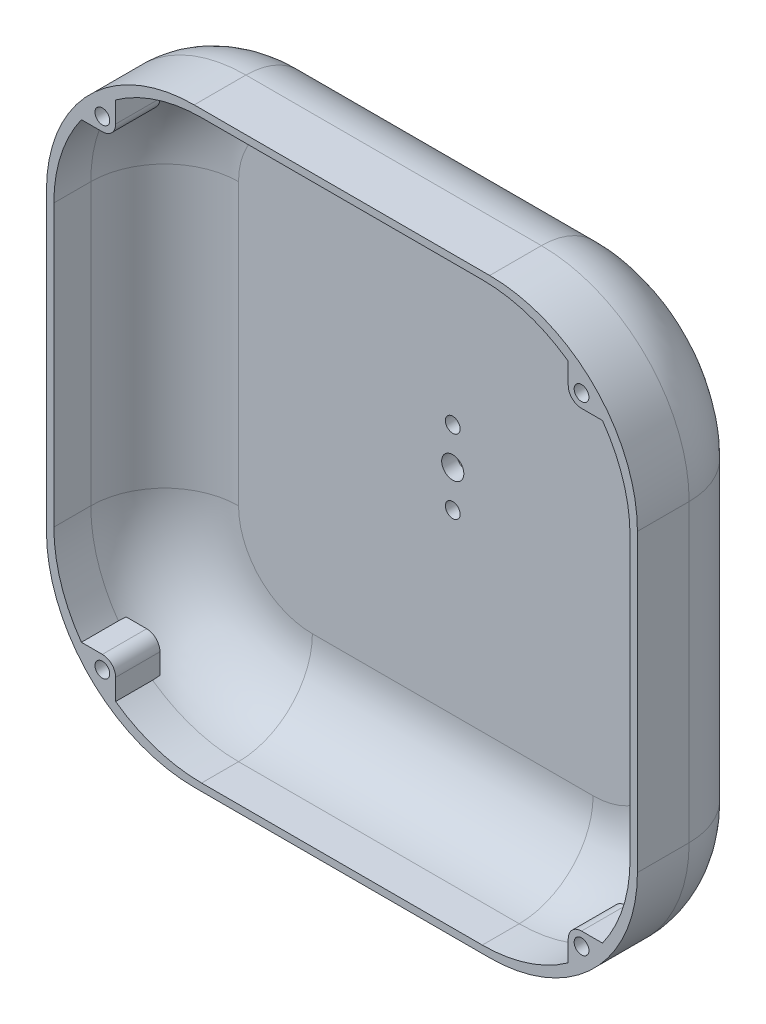
from build123d import *

# Parameters (mm, degrees)
SKETCH1_W           = 80
SKETCH1_H           = 80
BOSS_EXTRUDE1_DEPTH = 2
SKETCH2_W           = 80
SKETCH2_H           = 80
SKETCH2_W_2         = 78
SKETCH2_H_2         = 78
BOSS_EXTRUDE2_DEPTH = 15
FILLET1_R           = 20
FILLET2_R           = 10
FILLET3_R           = 20
FILLET4_R           = 10
SKETCH3_R           = 1
BOSS_EXTRUDE3_DEPTH = 6
SKETCH4_W           = 10
SKETCH4_H           = 10
BOSS_EXTRUDE4_DEPTH = 5
SKETCH5_W           = 6
SKETCH5_H           = 20
BOSS_EXTRUDE5_DEPTH = 20
CUT_EXTRUDE1_DEPTH  = 23
SKETCH7_R           = 2
CUT_EXTRUDE2_DEPTH  = 23
SKETCH8_R           = 3.5
CUT_EXTRUDE3_DEPTH  = 3
SKETCH9_R           = 1
CUT_EXTRUDE4_DEPTH  = 18
SKETCH10_R          = 1.5
CUT_EXTRUDE5_DEPTH  = 18
SKETCH12_W          = 51.714198926
SKETCH12_H          = 32.805177312
CUT_EXTRUDE7_DEPTH  = 37


with BuildPart() as part:
    # Sketch1 → Boss-Extrude1 (new body)
    with BuildSketch(Plane.XY):
        with Locations((40, 40)):
            Rectangle(SKETCH1_W, SKETCH1_H)
    extrude(amount=BOSS_EXTRUDE1_DEPTH)

    # Sketch2 → Boss-Extrude2 (add)
    with BuildSketch(Plane.XY.offset(2)):
        with Locations((40, 40)):
            Rectangle(SKETCH2_W, SKETCH2_H)
        with Locations((40, 40)):
            Rectangle(SKETCH2_W_2, SKETCH2_H_2, mode=Mode.SUBTRACT)
    extrude(amount=BOSS_EXTRUDE2_DEPTH)

    # Fillet1
    fillet1_edges = [part.edges().sort_by_distance(p)[0] for p in [
        (1, 79, 9.5),
        (1, 1, 9.5),
        (79, 1, 9.5),
        (79, 79, 9.5),
    ]]
    fillet(fillet1_edges, radius=FILLET1_R)

    # Fillet2
    fillet2_edges = [part.edges().sort_by_distance(p)[0] for p in [
        (40, 1, 2),
        (79, 40, 2),
        (40, 79, 2),
        (1, 40, 2),
        (6.857864376, 73.142135624, 2),
        (73.142135624, 73.142135624, 2),
        (6.857864376, 6.857864376, 2),
        (73.142135624, 6.857864376, 2),
    ]]
    fillet(fillet2_edges, radius=FILLET2_R)

    # Fillet3
    fillet3_edges = [part.edges().sort_by_distance(p)[0] for p in [
        (0, 80, 8.5),
        (80, 80, 8.5),
        (80, 0, 8.5),
        (0, 0, 8.5),
    ]]
    fillet(fillet3_edges, radius=FILLET3_R)

    # Fillet4
    fillet4_edges = [part.edges().sort_by_distance(p)[0] for p in [
        (80, 40, 0),
        (0, 40, 0),
        (40, 80, 0),
        (40, 0, 0),
        (5.857864376, 5.857864376, 0),
        (5.857864376, 74.142135624, 0),
        (74.142135624, 74.142135624, 0),
        (74.142135624, 5.857864376, 0),
    ]]
    fillet(fillet4_edges, radius=FILLET4_R)

    # Sketch3 → Boss-Extrude3 (add)
    with BuildSketch(Plane.XY.offset(17)):
        with BuildLine():
            Line((72.292824946, 5.37212195), (70.635028843, 4.105439789))
            Line((70.635028843, 4.105439789), (70.635028843, 7.564971157))
            ThreePointArc((70.635028843, 7.564971157), (71.162236636, 8.837763364), (72.435028843, 9.364971157))
            Line((72.435028843, 9.364971157), (76.003973901, 9.364971157))
            Line((76.003973901, 9.364971157), (72.292824946, 5.37212195))
        make_face()
        with Locations((72.435028843, 7.564971157)):
            Circle(SKETCH3_R, mode=Mode.SUBTRACT)
        with BuildLine():
            Line((9.364971157, 4.105439789), (9.364971157, 7.564971157))
            ThreePointArc((9.364971157, 7.564971157), (8.837763364, 8.837763364), (7.564971157, 9.364971157))
            Line((7.564971157, 9.364971157), (3.996026099, 9.364971157))
            Line((3.996026099, 9.364971157), (7.707175054, 5.37212195))
            Line((7.707175054, 5.37212195), (9.364971157, 4.105439789))
        make_face()
        with Locations((7.564971157, 7.564971157)):
            Circle(SKETCH3_R, mode=Mode.SUBTRACT)
        with BuildLine():
            Line((70.635028843, 75.894560211), (70.635028843, 72.435028843))
            ThreePointArc((70.635028843, 72.435028843), (71.162236636, 71.162236636), (72.435028843, 70.635028843))
            Line((72.435028843, 70.635028843), (76.003973901, 70.635028843))
            Line((76.003973901, 70.635028843), (72.292824946, 74.62787805))
            Line((72.292824946, 74.62787805), (70.635028843, 75.894560211))
        make_face()
        with Locations((72.435028843, 72.435028843)):
            Circle(SKETCH3_R, mode=Mode.SUBTRACT)
        with BuildLine():
            Line((7.707175054, 74.62787805), (9.364971157, 75.894560211))
            Line((9.364971157, 75.894560211), (9.364971157, 72.435028843))
            ThreePointArc((9.364971157, 72.435028843), (8.837763364, 71.162236636), (7.564971157, 70.635028843))
            Line((7.564971157, 70.635028843), (3.996026099, 70.635028843))
            Line((3.996026099, 70.635028843), (7.707175054, 74.62787805))
        make_face()
        with Locations((7.564971157, 72.435028843)):
            Circle(SKETCH3_R, mode=Mode.SUBTRACT)
    extrude(amount=-BOSS_EXTRUDE3_DEPTH)

    # Sketch4 → Boss-Extrude4 (add)
    with BuildSketch(Plane(origin=(0, 0, 0), x_dir=(-1, 0, 0), z_dir=(0, 0, -1))):
        with Locations((-35, 35)):
            Rectangle(SKETCH4_W, SKETCH4_H)
        with Locations((-35, 45)):
            Rectangle(SKETCH4_W, SKETCH4_H)
        with Locations((-45, 45)):
            Rectangle(SKETCH4_W, SKETCH4_H)
        with Locations((-45, 35)):
            Rectangle(SKETCH4_W, SKETCH4_H)
    extrude(amount=BOSS_EXTRUDE4_DEPTH)

    # Sketch5 → Boss-Extrude5 (add)
    with BuildSketch(Plane(origin=(0, 0, -5), x_dir=(-1, 0, 0), z_dir=(0, 0, -1))):
        with Locations((-33, 40)):
            Rectangle(SKETCH5_W, SKETCH5_H)
        with Locations((-47, 40)):
            Rectangle(SKETCH5_W, SKETCH5_H)
    extrude(amount=BOSS_EXTRUDE5_DEPTH)

    # Sketch6 → Cut-Extrude1 (cut)
    with BuildSketch(Plane.ZY.offset(-30)):
        with BuildLine():
            Line((-15, 30), (-19.756708154, 21.186247086))
            Line((-19.756708154, 21.186247086), (-29.168380108, 27.64799201))
            Line((-29.168380108, 27.64799201), (-29.168380108, 53.846153493))
            Line((-29.168380108, 53.846153493), (-15, 50))
            ThreePointArc((-15, 50), (-25, 40), (-15, 30))
        make_face()
    extrude(amount=-CUT_EXTRUDE1_DEPTH, mode=Mode.SUBTRACT)

    # Sketch7 → Cut-Extrude2 (cut)
    with BuildSketch(Plane.ZY.offset(-30)):
        with Locations((-15, 40)):
            Circle(SKETCH7_R)
    extrude(amount=-CUT_EXTRUDE2_DEPTH, mode=Mode.SUBTRACT)

    # Sketch8 → Cut-Extrude3 (cut)
    with BuildSketch(Plane.ZY.offset(-30)):
        with Locations((-15, 40)):
            Circle(SKETCH8_R)
    extrude(amount=-CUT_EXTRUDE3_DEPTH, mode=Mode.SUBTRACT)

    # Sketch9 → Cut-Extrude4 (cut)
    with BuildSketch(Plane(origin=(0, 0, -5), x_dir=(-1, 0, 0), z_dir=(0, 0, -1))):
        with Locations((-40, 45)):
            Circle(SKETCH9_R)
        with Locations((-40, 35)):
            Circle(SKETCH9_R)
    extrude(amount=-CUT_EXTRUDE4_DEPTH, mode=Mode.SUBTRACT)

    # Sketch10 → Cut-Extrude5 (cut)
    with BuildSketch(Plane(origin=(0, 0, -5), x_dir=(-1, 0, 0), z_dir=(0, 0, -1))):
        with Locations((-40, 40)):
            Circle(SKETCH10_R)
    extrude(amount=-CUT_EXTRUDE5_DEPTH, mode=Mode.SUBTRACT)

    # Sketch12 → Cut-Extrude7 (cut)
    with BuildSketch(Plane.XZ.offset(-30)):
        with Locations((40.307091443, -16.402588656)):
            Rectangle(SKETCH12_W, SKETCH12_H)
    extrude(amount=-CUT_EXTRUDE7_DEPTH, mode=Mode.SUBTRACT)


solid = part.part
